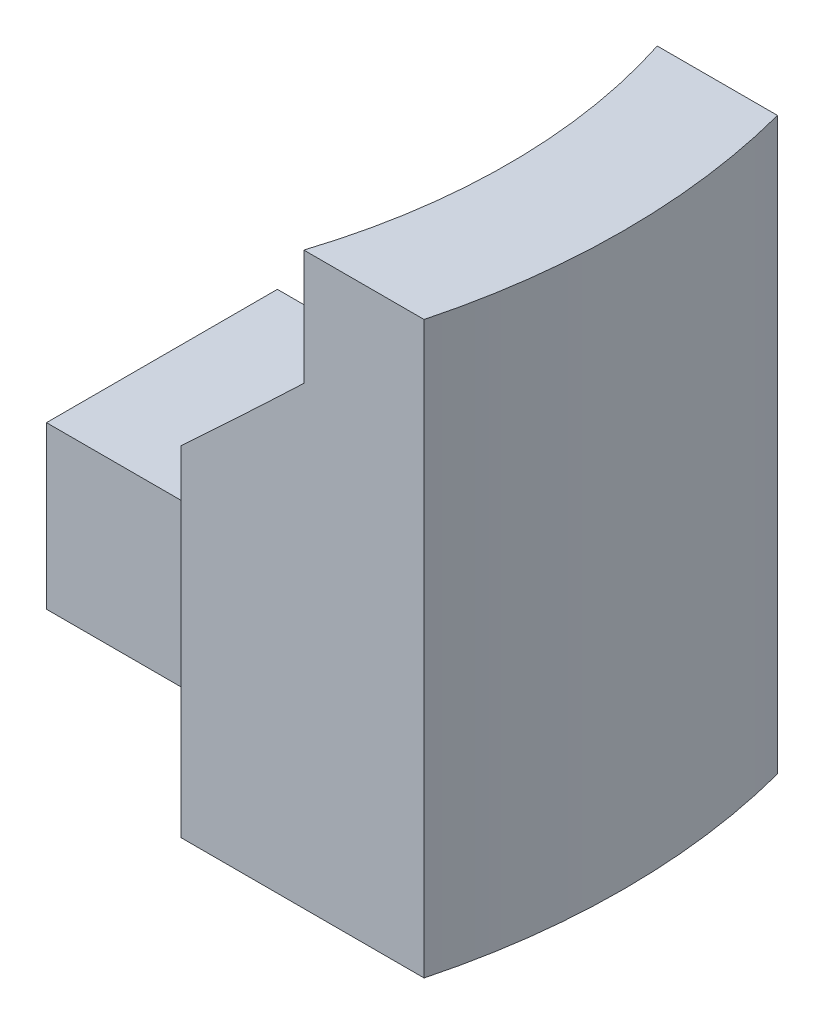
from build123d import *

# Parameters (mm, degrees)
REVOLVE1_ANGLE          = 45
SKETCH3_W               = 5
SKETCH3_H               = 5
BOSS_EXTRUDE2_DEPTH     = 5
CHAMFER2_SIZE           = 1.5
CUT_EXTRUDE1_DEPTH      = 1
CUT_EXTRUDE1_DEPTH_BACK = 13.35


with BuildPart() as part:
    # Sketch2 → Revolve1 (revolve, symmetric)
    with BuildSketch(Plane.XY) as revolve1_sk:
        Polygon((0, 0), (5, 0), (5, 12.35), (2.5, 12.35), (2.5, 9.85), (0, 7.35), align=None)
    revolve(axis=Axis((-10, 0, 0), (0, 1, 0)), revolution_arc=REVOLVE1_ANGLE / 2)
    revolve(revolve1_sk.sketch, axis=Axis((-10, 0, 0), (0, -1, 0)), revolution_arc=REVOLVE1_ANGLE / 2)

    # Sketch3 → Boss-Extrude2 (add)
    with BuildSketch(Plane(origin=(0, 0, 0), x_dir=(0, 0, -1), z_dir=(1, 0, 0))):
        with Locations((0, 2.5)):
            Rectangle(SKETCH3_W, SKETCH3_H)
    extrude(amount=-BOSS_EXTRUDE2_DEPTH)

    # Chamfer2
    chamfer2_edges = [part.edges().sort_by_distance(p)[0] for p in [
        (-2.658770817, 0, -2.5),
        (-2.658770817, 0, 2.5),
    ]]
    chamfer(chamfer2_edges, length=CHAMFER2_SIZE)

    # Sketch4 → Cut-Extrude1 (cut, two sides)
    with BuildSketch(Plane.XZ) as cut_extrude1_sk:
        with BuildLine():
            Line((-0.761204675, 3.826834324), (4.503631926, 3.826834324))
            ThreePointArc((4.503631926, 3.826834324), (4.213147766, 4.794416604), (3.858192988, 5.740251485))
            Line((3.858192988, 5.740251485), (-0.761204675, 3.826834324))
        make_face()
        with BuildLine():
            Line((-0.761204675, -3.826834324), (4.503631926, -3.826834324))
            ThreePointArc((4.503631926, -3.826834324), (4.213147766, -4.794416604), (3.858192988, -5.740251485))
            Line((3.858192988, -5.740251485), (-0.761204675, -3.826834324))
        make_face()
    extrude(amount=CUT_EXTRUDE1_DEPTH, mode=Mode.SUBTRACT)
    extrude(cut_extrude1_sk.sketch, amount=-CUT_EXTRUDE1_DEPTH_BACK, mode=Mode.SUBTRACT)


solid = part.part
